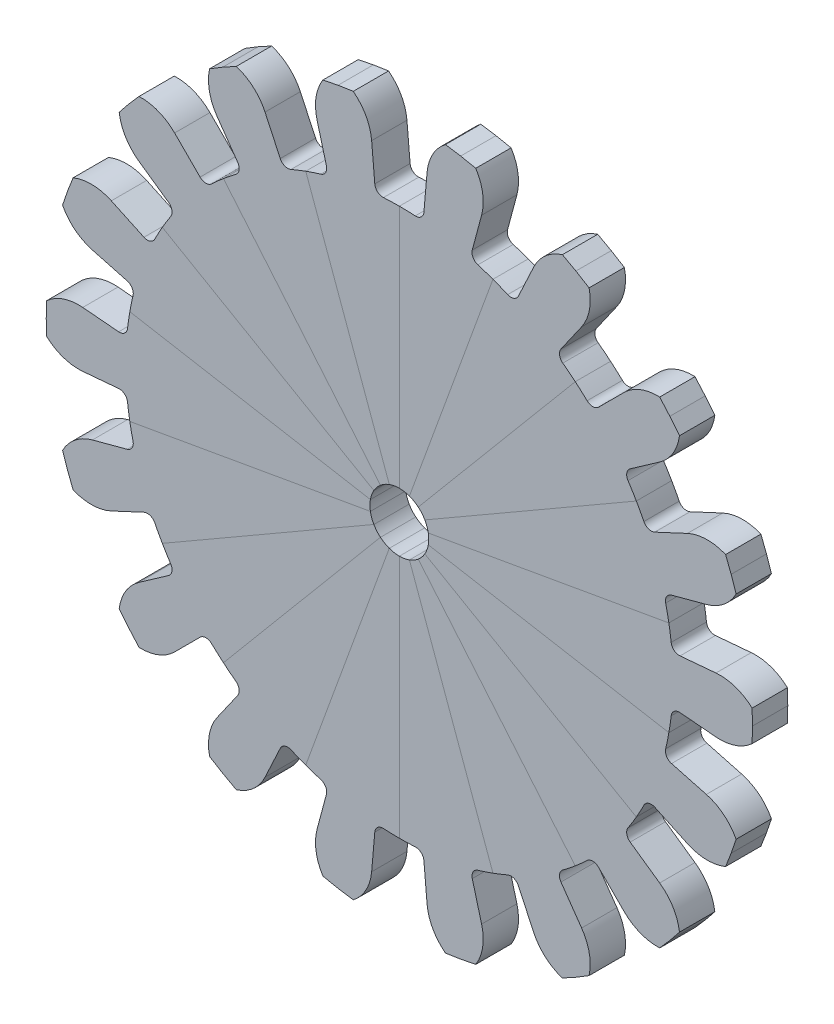
from build123d import *

# Parameters (mm, degrees)
BOSS_EXTRU_4_DEPTH           = 3
CONG_1_R                     = 0.7
R_P_TITION_CIRCULAIRE1_COUNT = 18
ESQUISSE5_R                  = 2.5
ENL_V_MAT_EXTRU_1_DEPTH      = 4


with BuildPart() as part:
    # Esquisse4 → Boss.-Extru.4 (new body)
    with BuildSketch(Plane.XY):
        with BuildLine():
            ThreePointArc((23.161526731, -2.026371019), (23.051093027, -3.034733969), (22.896780258, -4.037320131))
            Line((22.896780258, -4.037320131), (0, 0))
            Line((0, 0), (22.896780258, 4.037320131))
            ThreePointArc((22.896780258, 4.037320131), (23.051093027, 3.034733969), (23.161526731, 2.026371019))
            Line((23.161526731, 2.026371019), (26.897256848, 2.353205054))
            ThreePointArc((26.897256848, 2.353205054), (28.54426772, 2.15436163), (29.971446647, 1.308581621))
            Line((29.971446647, 1.308581621), (30, 0))
            Line((30, 0), (29.971446647, -1.308581621))
            ThreePointArc((29.971446647, -1.308581621), (28.54426772, -2.15436163), (26.897256848, -2.353205054))
            Line((26.897256848, -2.353205054), (23.161526731, -2.026371019))
        make_face()
    extrude(amount=BOSS_EXTRU_4_DEPTH)

    # Congé1
    cong_1_edges = [part.edges().sort_by_distance(p)[0] for p in [
        (23.161526731, 2.026371019, 1.5),
        (23.161526731, -2.026371019, 1.5),
    ]]
    fillet(cong_1_edges, radius=CONG_1_R)


with BuildPart() as r_p_tition_circulaire1_1:
    # Répétition circulaire1: pattern copy
    add(part.part.rotate(Axis((0, 0, 0), (0, 0, 1)), 1 * 360 / R_P_TITION_CIRCULAIRE1_COUNT))


with BuildPart() as r_p_tition_circulaire1_2:
    # Répétition circulaire1: pattern copy
    add(part.part.rotate(Axis((0, 0, 0), (0, 0, 1)), 2 * 360 / R_P_TITION_CIRCULAIRE1_COUNT))


with BuildPart() as r_p_tition_circulaire1_3:
    # Répétition circulaire1: pattern copy
    add(part.part.rotate(Axis((0, 0, 0), (0, 0, 1)), 3 * 360 / R_P_TITION_CIRCULAIRE1_COUNT))


with BuildPart() as r_p_tition_circulaire1_4:
    # Répétition circulaire1: pattern copy
    add(part.part.rotate(Axis((0, 0, 0), (0, 0, 1)), 4 * 360 / R_P_TITION_CIRCULAIRE1_COUNT))


with BuildPart() as r_p_tition_circulaire1_5:
    # Répétition circulaire1: pattern copy
    add(part.part.rotate(Axis((0, 0, 0), (0, 0, 1)), 5 * 360 / R_P_TITION_CIRCULAIRE1_COUNT))


with BuildPart() as r_p_tition_circulaire1_6:
    # Répétition circulaire1: pattern copy
    add(part.part.rotate(Axis((0, 0, 0), (0, 0, 1)), 6 * 360 / R_P_TITION_CIRCULAIRE1_COUNT))


with BuildPart() as r_p_tition_circulaire1_7:
    # Répétition circulaire1: pattern copy
    add(part.part.rotate(Axis((0, 0, 0), (0, 0, 1)), 7 * 360 / R_P_TITION_CIRCULAIRE1_COUNT))


with BuildPart() as r_p_tition_circulaire1_8:
    # Répétition circulaire1: pattern copy
    add(part.part.rotate(Axis((0, 0, 0), (0, 0, 1)), 8 * 360 / R_P_TITION_CIRCULAIRE1_COUNT))


with BuildPart() as r_p_tition_circulaire1_9:
    # Répétition circulaire1: pattern copy
    add(part.part.rotate(Axis((0, 0, 0), (0, 0, 1)), 9 * 360 / R_P_TITION_CIRCULAIRE1_COUNT))


with BuildPart() as r_p_tition_circulaire1_10:
    # Répétition circulaire1: pattern copy
    add(part.part.rotate(Axis((0, 0, 0), (0, 0, 1)), 10 * 360 / R_P_TITION_CIRCULAIRE1_COUNT))


with BuildPart() as r_p_tition_circulaire1_11:
    # Répétition circulaire1: pattern copy
    add(part.part.rotate(Axis((0, 0, 0), (0, 0, 1)), 11 * 360 / R_P_TITION_CIRCULAIRE1_COUNT))


with BuildPart() as r_p_tition_circulaire1_12:
    # Répétition circulaire1: pattern copy
    add(part.part.rotate(Axis((0, 0, 0), (0, 0, 1)), 12 * 360 / R_P_TITION_CIRCULAIRE1_COUNT))


with BuildPart() as r_p_tition_circulaire1_13:
    # Répétition circulaire1: pattern copy
    add(part.part.rotate(Axis((0, 0, 0), (0, 0, 1)), 13 * 360 / R_P_TITION_CIRCULAIRE1_COUNT))


with BuildPart() as r_p_tition_circulaire1_14:
    # Répétition circulaire1: pattern copy
    add(part.part.rotate(Axis((0, 0, 0), (0, 0, 1)), 14 * 360 / R_P_TITION_CIRCULAIRE1_COUNT))


with BuildPart() as r_p_tition_circulaire1_15:
    # Répétition circulaire1: pattern copy
    add(part.part.rotate(Axis((0, 0, 0), (0, 0, 1)), 15 * 360 / R_P_TITION_CIRCULAIRE1_COUNT))


with BuildPart() as r_p_tition_circulaire1_16:
    # Répétition circulaire1: pattern copy
    add(part.part.rotate(Axis((0, 0, 0), (0, 0, 1)), 16 * 360 / R_P_TITION_CIRCULAIRE1_COUNT))


with BuildPart() as r_p_tition_circulaire1_17:
    # Répétition circulaire1: pattern copy
    add(part.part.rotate(Axis((0, 0, 0), (0, 0, 1)), 17 * 360 / R_P_TITION_CIRCULAIRE1_COUNT))


with BuildPart() as enl_v_mat_extru_1_tool:
    # Esquisse5 → Enlèv. mat.-Extru.1 (new body, through all)
    with BuildSketch(Plane(origin=(0, 0, 0), x_dir=(-1, 0, 0), z_dir=(0, 0, -1))):
        Circle(ESQUISSE5_R)
    extrude(amount=-ENL_V_MAT_EXTRU_1_DEPTH)


with BuildPart() as part_1:
    add(part.part)

    # Enlèv. mat.-Extru.1: cut by enl_v_mat_extru_1_tool
    add(enl_v_mat_extru_1_tool.part, mode=Mode.SUBTRACT)


with BuildPart() as r_p_tition_circulaire1_1_1:
    add(r_p_tition_circulaire1_1.part)

    # Enlèv. mat.-Extru.1: cut by enl_v_mat_extru_1_tool
    add(enl_v_mat_extru_1_tool.part, mode=Mode.SUBTRACT)


with BuildPart() as r_p_tition_circulaire1_2_1:
    add(r_p_tition_circulaire1_2.part)

    # Enlèv. mat.-Extru.1: cut by enl_v_mat_extru_1_tool
    add(enl_v_mat_extru_1_tool.part, mode=Mode.SUBTRACT)


with BuildPart() as r_p_tition_circulaire1_3_1:
    add(r_p_tition_circulaire1_3.part)

    # Enlèv. mat.-Extru.1: cut by enl_v_mat_extru_1_tool
    add(enl_v_mat_extru_1_tool.part, mode=Mode.SUBTRACT)


with BuildPart() as r_p_tition_circulaire1_4_1:
    add(r_p_tition_circulaire1_4.part)

    # Enlèv. mat.-Extru.1: cut by enl_v_mat_extru_1_tool
    add(enl_v_mat_extru_1_tool.part, mode=Mode.SUBTRACT)


with BuildPart() as r_p_tition_circulaire1_5_1:
    add(r_p_tition_circulaire1_5.part)

    # Enlèv. mat.-Extru.1: cut by enl_v_mat_extru_1_tool
    add(enl_v_mat_extru_1_tool.part, mode=Mode.SUBTRACT)


with BuildPart() as r_p_tition_circulaire1_6_1:
    add(r_p_tition_circulaire1_6.part)

    # Enlèv. mat.-Extru.1: cut by enl_v_mat_extru_1_tool
    add(enl_v_mat_extru_1_tool.part, mode=Mode.SUBTRACT)


with BuildPart() as r_p_tition_circulaire1_7_1:
    add(r_p_tition_circulaire1_7.part)

    # Enlèv. mat.-Extru.1: cut by enl_v_mat_extru_1_tool
    add(enl_v_mat_extru_1_tool.part, mode=Mode.SUBTRACT)


with BuildPart() as r_p_tition_circulaire1_8_1:
    add(r_p_tition_circulaire1_8.part)

    # Enlèv. mat.-Extru.1: cut by enl_v_mat_extru_1_tool
    add(enl_v_mat_extru_1_tool.part, mode=Mode.SUBTRACT)


with BuildPart() as r_p_tition_circulaire1_9_1:
    add(r_p_tition_circulaire1_9.part)

    # Enlèv. mat.-Extru.1: cut by enl_v_mat_extru_1_tool
    add(enl_v_mat_extru_1_tool.part, mode=Mode.SUBTRACT)


with BuildPart() as r_p_tition_circulaire1_10_1:
    add(r_p_tition_circulaire1_10.part)

    # Enlèv. mat.-Extru.1: cut by enl_v_mat_extru_1_tool
    add(enl_v_mat_extru_1_tool.part, mode=Mode.SUBTRACT)


with BuildPart() as r_p_tition_circulaire1_11_1:
    add(r_p_tition_circulaire1_11.part)

    # Enlèv. mat.-Extru.1: cut by enl_v_mat_extru_1_tool
    add(enl_v_mat_extru_1_tool.part, mode=Mode.SUBTRACT)


with BuildPart() as r_p_tition_circulaire1_12_1:
    add(r_p_tition_circulaire1_12.part)

    # Enlèv. mat.-Extru.1: cut by enl_v_mat_extru_1_tool
    add(enl_v_mat_extru_1_tool.part, mode=Mode.SUBTRACT)


with BuildPart() as r_p_tition_circulaire1_13_1:
    add(r_p_tition_circulaire1_13.part)

    # Enlèv. mat.-Extru.1: cut by enl_v_mat_extru_1_tool
    add(enl_v_mat_extru_1_tool.part, mode=Mode.SUBTRACT)


with BuildPart() as r_p_tition_circulaire1_14_1:
    add(r_p_tition_circulaire1_14.part)

    # Enlèv. mat.-Extru.1: cut by enl_v_mat_extru_1_tool
    add(enl_v_mat_extru_1_tool.part, mode=Mode.SUBTRACT)


with BuildPart() as r_p_tition_circulaire1_15_1:
    add(r_p_tition_circulaire1_15.part)

    # Enlèv. mat.-Extru.1: cut by enl_v_mat_extru_1_tool
    add(enl_v_mat_extru_1_tool.part, mode=Mode.SUBTRACT)


with BuildPart() as r_p_tition_circulaire1_16_1:
    add(r_p_tition_circulaire1_16.part)

    # Enlèv. mat.-Extru.1: cut by enl_v_mat_extru_1_tool
    add(enl_v_mat_extru_1_tool.part, mode=Mode.SUBTRACT)


with BuildPart() as r_p_tition_circulaire1_17_1:
    add(r_p_tition_circulaire1_17.part)

    # Enlèv. mat.-Extru.1: cut by enl_v_mat_extru_1_tool
    add(enl_v_mat_extru_1_tool.part, mode=Mode.SUBTRACT)


solid = Compound([part_1.part, r_p_tition_circulaire1_1_1.part, r_p_tition_circulaire1_2_1.part, r_p_tition_circulaire1_3_1.part, r_p_tition_circulaire1_4_1.part, r_p_tition_circulaire1_5_1.part, r_p_tition_circulaire1_6_1.part, r_p_tition_circulaire1_7_1.part, r_p_tition_circulaire1_8_1.part, r_p_tition_circulaire1_9_1.part, r_p_tition_circulaire1_10_1.part, r_p_tition_circulaire1_11_1.part, r_p_tition_circulaire1_12_1.part, r_p_tition_circulaire1_13_1.part, r_p_tition_circulaire1_14_1.part, r_p_tition_circulaire1_15_1.part, r_p_tition_circulaire1_16_1.part, r_p_tition_circulaire1_17_1.part])
